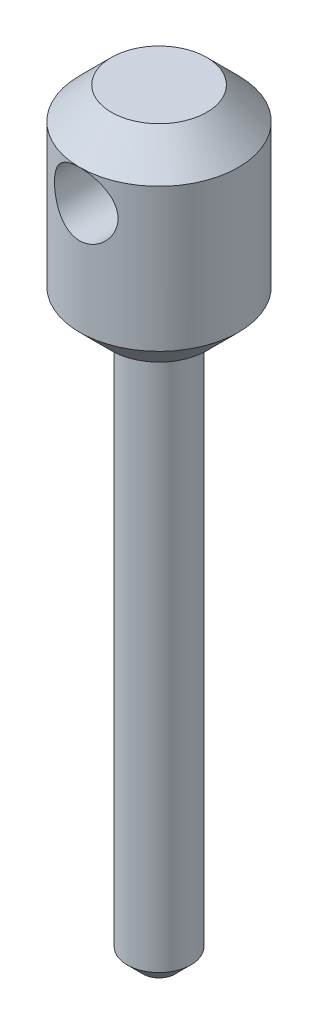
from build123d import *

# Parameters (mm, degrees)
SKETCH2_R               = 2
CUT_EXTRUDE1_DEPTH      = 6
CUT_EXTRUDE1_DEPTH_BACK = 6


with BuildPart() as part:
    # Sketch1 → Revolve1 (revolve)
    with BuildSketch(Plane.XY):
        Polygon((0, 0), (1, 0), (2, 1), (2, 35), (3, 35), (5, 37), (5, 46), (3, 48), (0, 48), align=None)
    revolve(axis=Axis((0, 0, 0), (0, 1, 0)))

    # Sketch2 → Cut-Extrude1 (cut, two sides)
    with BuildSketch(Plane.XY) as cut_extrude1_sk:
        with Locations((0, 44)):
            Circle(SKETCH2_R)
    extrude(amount=CUT_EXTRUDE1_DEPTH, mode=Mode.SUBTRACT)
    extrude(cut_extrude1_sk.sketch, amount=-CUT_EXTRUDE1_DEPTH_BACK, mode=Mode.SUBTRACT)


solid = part.part
